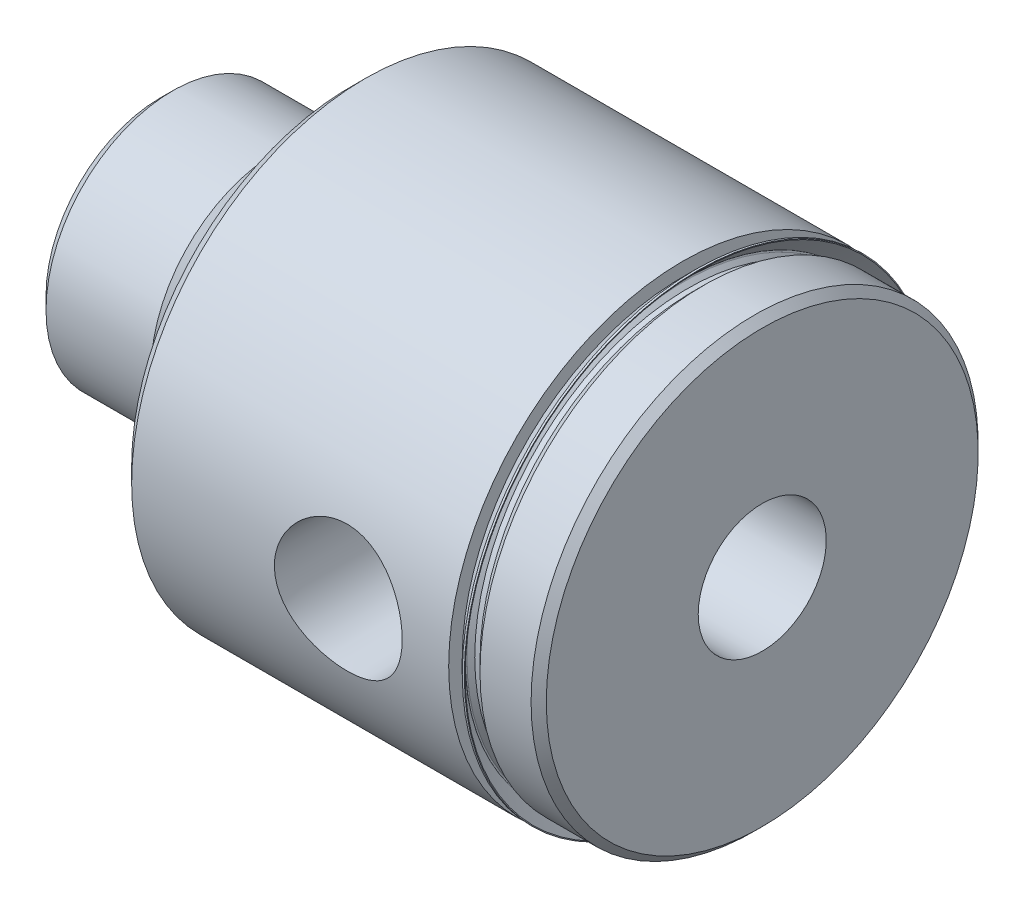
from build123d import *

# Parameters (mm, degrees)
HOLE1_D           = 12.827
HOLE1_CSINK_D     = 14.351
HOLE1_CSINK_ANGLE = 90


with BuildPart() as part:
    # Sketch1 → Revolve1 (revolve)
    with BuildSketch(Plane.XY):
        with BuildLine():
            Line((0, 0), (0, 11.43127))
            Line((0, 11.43127), (1.26873, 12.7))
            Line((1.26873, 12.7), (11.786186437, 12.7))
            Line((11.786186437, 12.7), (13.129150664, 11.570773334))
            ThreePointArc((13.129150664, 11.570773334), (13.480921475, 11.367317925), (13.8811, 11.29665))
            Line((13.8811, 11.29665), (15.494, 11.29665))
            ThreePointArc((15.494, 11.29665), (16.320183563, 11.638866437), (16.6624, 12.46505))
            Line((16.6624, 12.46505), (16.6624, 13.08735))
            Line((16.6624, 13.08735), (19.05, 13.08735))
            Line((19.05, 13.08735), (19.05, 0))
            Line((19.05, 0), (0, 0))
        make_face()
    revolve(axis=Axis((19.05, 0, 0), (-1, 0, 0)))

    # Sketch2 → Revolve2 (revolve)
    with BuildSketch(Plane.XY):
        Polygon((19.05, 0), (19.05, 21.90115), (20.574, 23.42515), (52.3367, 23.42515), (52.3367, 21.34235), (53.3908, 21.34235), (54.4449, 22.39645), (59.563, 22.39645), (60.325, 21.63445), (60.325, 0), align=None)
    revolve(axis=Axis((60.325, 0, 0), (-1, 0, 0)))

    # Hole1 (through all)
    with Locations(Plane.ZY):
        with Locations((0, 0)):
            CounterSinkHole(HOLE1_D / 2, HOLE1_CSINK_D / 2, counter_sink_angle=HOLE1_CSINK_ANGLE)

    # Sketch5 → Cut-Revolve1 (revolve, cut)
    with BuildSketch(Plane(origin=(0, 0, 0), x_dir=(1, 0, 0), z_dir=(0, 1, 0))):
        Polygon((41.275, 0), (44.45, 0), (44.45, -5.926053545), (47.217096455, -8.69315), (47.677022746, -23.42515), (41.275, -23.42515), align=None)
    revolve(axis=Axis((41.275, 0, 23.42515), (0, 0, -1)), mode=Mode.SUBTRACT)

    # Sketch6 → Revolve3 (revolve)
    with BuildSketch(Plane.XY):
        with BuildLine():
            Line((52.3367, 21.08835), (53.3908, 21.08835))
            Line((53.3908, 21.08835), (53.3908, 21.34235))
            Line((53.3908, 21.34235), (52.86375, 21.34235))
            Line((52.86375, 21.34235), (52.471716303, 21.734383697))
            ThreePointArc((52.471716303, 21.734383697), (52.434518864, 21.824186258), (52.471716303, 21.913988819))
            Line((52.471716303, 21.913988819), (53.898709288, 23.340981804))
            Line((53.898709288, 23.340981804), (53.898709288, 23.42515))
            Line((53.898709288, 23.42515), (53.695509288, 23.42515))
            Line((53.695509288, 23.42515), (52.3367, 22.066340712))
            Line((52.3367, 22.066340712), (52.3367, 21.08835))
        make_face()
    revolve(axis=Axis((53.3908, 0, 0), (-1, 0, 0)))


solid = part.part
